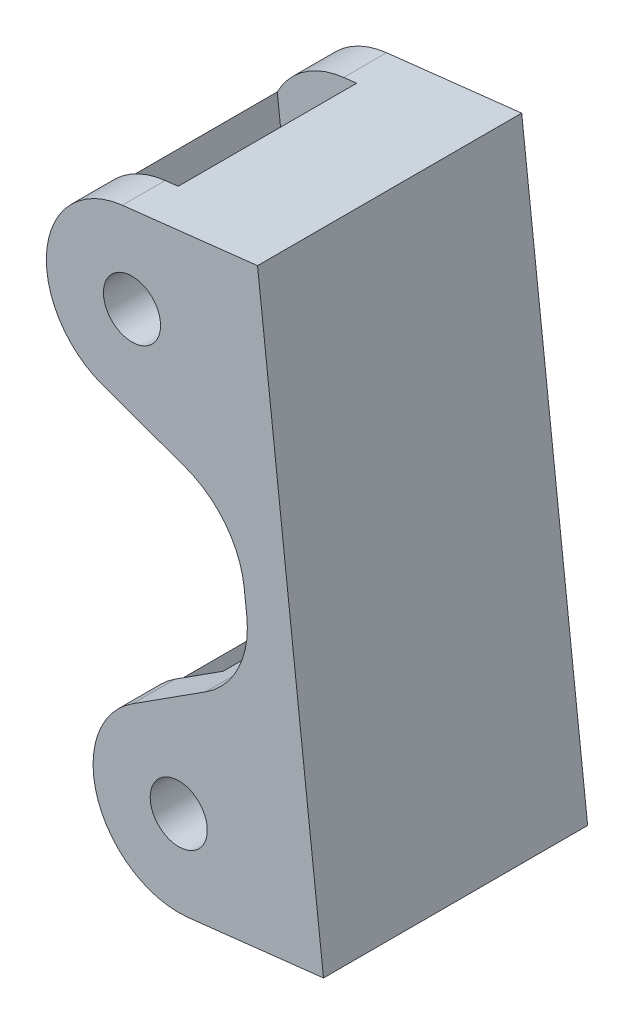
from build123d import *

# Parameters (mm, degrees)
SKETCH2_R           = 4
BOSS_EXTRUDE1_DEPTH = 18.5
SKETCH3_W           = 11.7897503
SKETCH3_H           = 96.005071975
CUT_EXTRUDE1_DEPTH  = 12.5


with BuildPart() as part:
    # Sketch2 → Boss-Extrude1 (new body, symmetric)
    with BuildSketch(Plane(origin=(137.548518754, -674.152855032, 0), x_dir=(0.993680552, 0.112245088, 0), z_dir=(0, 0, -1))):
        with BuildLine():
            Line((9.525, -304.744352791), (28.575, -304.744352791))
            Line((28.575, -304.744352791), (28.575, -387.05564726))
            Line((28.575, -387.05564726), (9.525993953, -387.05564726))
            ThreePointArc((9.525993953, -387.05564726), (-2.161189853, -377.777730047), (4.223746974, -364.290603044))
            Line((4.223746974, -364.290603044), (15.13654472, -358.9155811))
            ThreePointArc((15.13654472, -358.9155811), (20.308242044, -354.231651246), (22.225, -347.522575972))
            Line((22.225, -347.522575972), (22.225, -344.276661697))
            ThreePointArc((22.225, -344.276661697), (20.30793231, -337.567088625), (15.135492786, -332.883138506))
            Line((15.135492786, -332.883138506), (4.223746974, -327.509886515))
            ThreePointArc((4.223746974, -327.509886515), (-2.162309457, -314.022809542), (9.525, -304.744352791))
        make_face()
        with Locations((9.525993953, -375.05564726)):
            Circle(SKETCH2_R, mode=Mode.SUBTRACT)
        with Locations((9.525, -316.744352791)):
            Circle(SKETCH2_R, mode=Mode.SUBTRACT)
    extrude(amount=BOSS_EXTRUDE1_DEPTH, both=True)

    # Sketch3 → Cut-Extrude1 (cut, symmetric)
    with BuildSketch(Plane(origin=(140.134572942, -673.053475883, 0), x_dir=(0.993680552, 0.112245088, 0), z_dir=(0, 0, -1))):
        with Locations((2.760437102, -344.382335899)):
            Rectangle(SKETCH3_W, SKETCH3_H)
    extrude(amount=CUT_EXTRUDE1_DEPTH, both=True, mode=Mode.SUBTRACT)


solid = part.part
